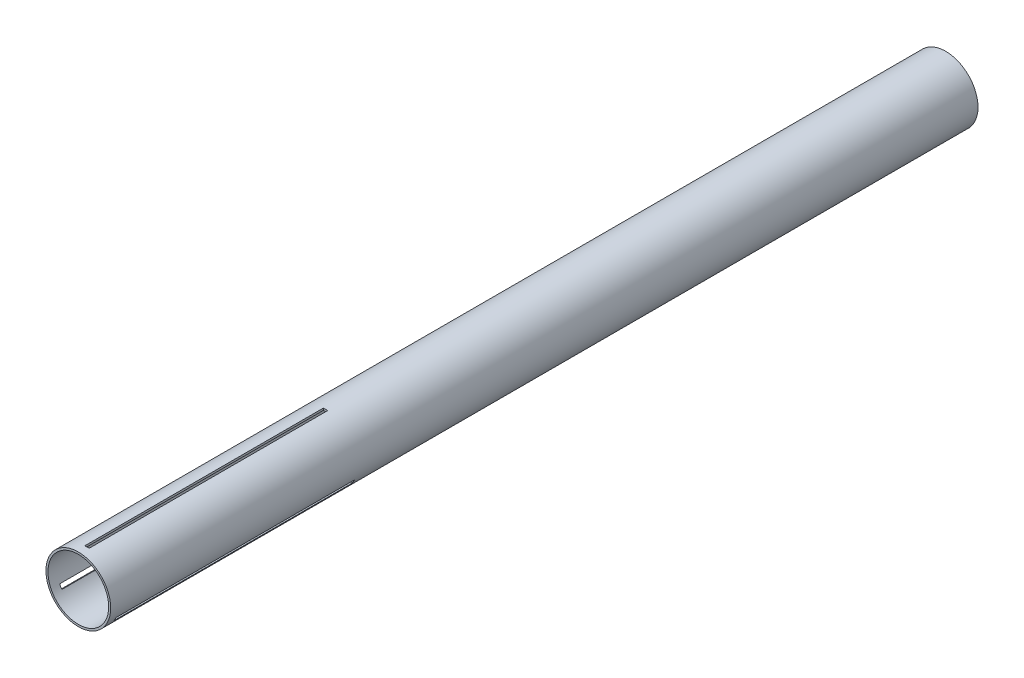
from build123d import *

# Parameters (mm, degrees)
SKETCH1_R           = 23.6982
SKETCH1_R_2         = 22.225
BOSS_EXTRUDE1_DEPTH = 635
CUT_EXTRUDE2_START  = -28.631769
SKETCH3_W           = 3.175
SKETCH3_H           = 174.625
CUT_EXTRUDE2_DEPTH  = 1.529969
CIRPATTERN4_COUNT   = 3


with BuildPart() as part:
    # Sketch1 → Boss-Extrude1 (new body)
    with BuildSketch(Plane.XY):
        Circle(SKETCH1_R)
        Circle(SKETCH1_R_2, mode=Mode.SUBTRACT)
    extrude(amount=BOSS_EXTRUDE1_DEPTH)

    # Sketch3 → Cut-Extrude2 (cut)
    with BuildSketch(Plane(origin=(0, 50.8, 0), x_dir=(1, 0, 0), z_dir=(0, 1, 0)).offset(CUT_EXTRUDE2_START)):
        with Locations((0, -541.3375)):
            Rectangle(SKETCH3_W, SKETCH3_H)
    cut_extrude2 = extrude(amount=CUT_EXTRUDE2_DEPTH, mode=Mode.SUBTRACT)

    # CirPattern4: Cut-Extrude2 ×3 about axis
    cirpattern4_axis = Axis((0, 0, 0), (0, 0, 1))
    for i in range(1, CIRPATTERN4_COUNT):
        add(cut_extrude2.rotate(cirpattern4_axis, i * 360 / CIRPATTERN4_COUNT), mode=Mode.SUBTRACT)


solid = part.part
